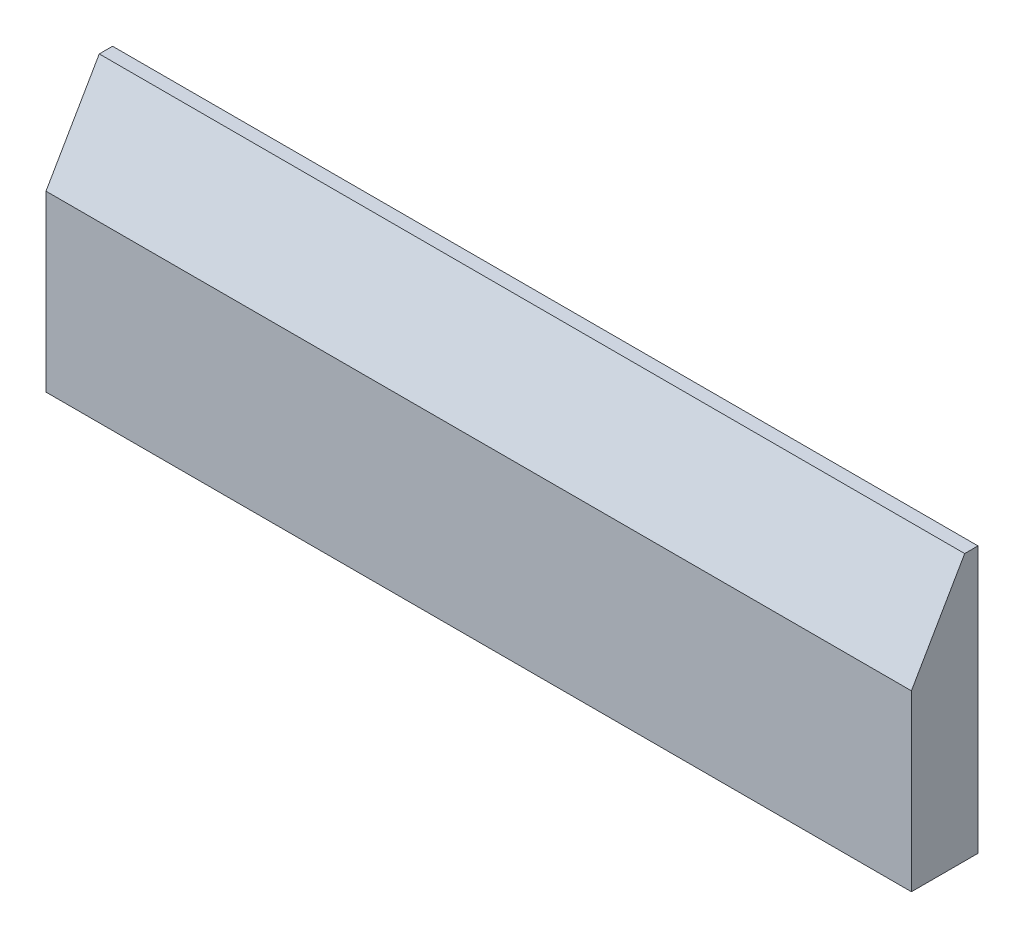
from build123d import *

# Parameters (mm, degrees)
SKETCH1_W           = 82.55
SKETCH1_H           = 25.4
BOSS_EXTRUDE1_DEPTH = 6.35
CHAMFER1_SIZE       = 5.08
CHAMFER1_SIZE2      = 8.798818102


with BuildPart() as part:
    # Sketch1 → Boss-Extrude1 (new body)
    with BuildSketch(Plane.XY):
        with Locations((41.275, 12.7)):
            Rectangle(SKETCH1_W, SKETCH1_H)
    extrude(amount=BOSS_EXTRUDE1_DEPTH)

    # Chamfer1
    chamfer1_edges = [part.edges().sort_by_distance(p)[0] for p in [
        (41.275, 25.4, 6.35),
    ]]
    chamfer1_side = [part.faces().sort_by_distance(p)[0] for p in [
        (41.275, 25.4, 3.175),
    ]]
    chamfer(chamfer1_edges, length=CHAMFER1_SIZE, length2=CHAMFER1_SIZE2, reference=chamfer1_side[0])


solid = part.part
